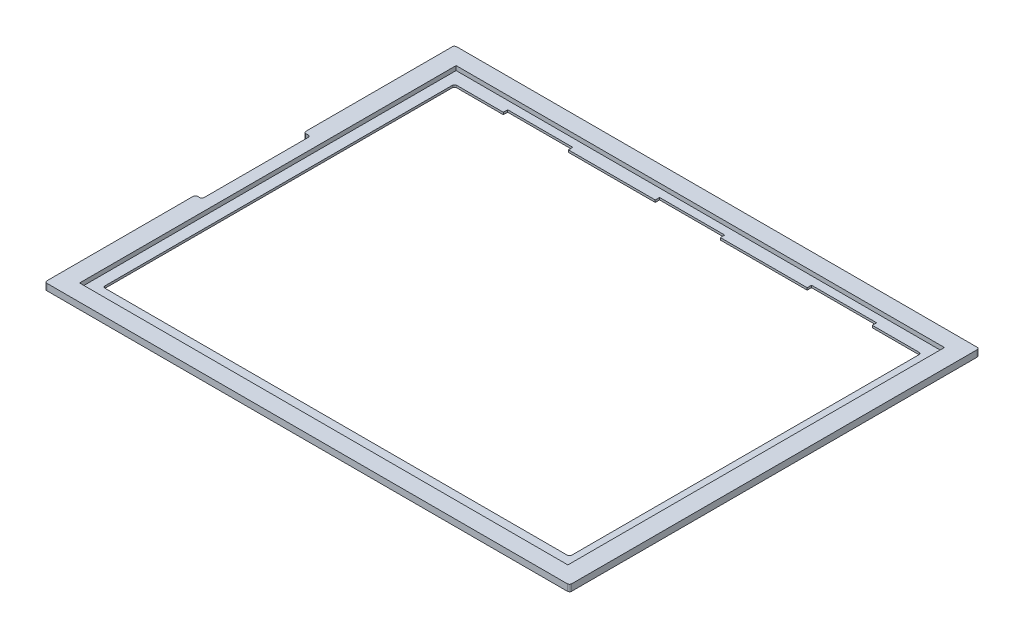
from build123d import *

# Parameters (mm, degrees)
SKETCH1_W           = 241.8
SKETCH1_H           = 188.8
SKETCH1_W_2         = 215
SKETCH1_H_2         = 162
BOSS_EXTRUDE1_DEPTH = 3
SKETCH2_W           = 225
SKETCH2_H           = 173.5
CUT_EXTRUDE1_DEPTH  = 2
SKETCH3_W           = 3
SKETCH3_H           = 50
CUT_EXTRUDE2_DEPTH  = 5
FILLET1_R           = 1
SKETCH4_W           = 30
SKETCH4_H           = 2
CUT_EXTRUDE3_DEPTH  = 4


with BuildPart() as part:
    # Sketch1 → Boss-Extrude1 (new body)
    with BuildSketch(Plane(origin=(0, 0, 0), x_dir=(1, 0, 0), z_dir=(0, 1, 0))):
        with Locations((120.9, 94.4)):
            Rectangle(SKETCH1_W, SKETCH1_H)
        with Locations((120.9, 94.4)):
            Rectangle(SKETCH1_W_2, SKETCH1_H_2, mode=Mode.SUBTRACT)
    extrude(amount=BOSS_EXTRUDE1_DEPTH)

    # Sketch2 → Cut-Extrude1 (cut)
    with BuildSketch(Plane(origin=(0, 3, 0), x_dir=(1, 0, 0), z_dir=(0, 1, 0))):
        with Locations((120.9, 94.4)):
            Rectangle(SKETCH2_W, SKETCH2_H)
    extrude(amount=-CUT_EXTRUDE1_DEPTH, mode=Mode.SUBTRACT)

    # Sketch3 → Cut-Extrude2 (cut)
    with BuildSketch(Plane(origin=(0, 3, 0), x_dir=(1, 0, 0), z_dir=(0, 1, 0))):
        with Locations((1.5, 94.4)):
            Rectangle(SKETCH3_W, SKETCH3_H)
    extrude(amount=-CUT_EXTRUDE2_DEPTH, mode=Mode.SUBTRACT)

    # Fillet1
    fillet1_edges = [part.edges().sort_by_distance(p)[0] for p in [
        (228.4, 0.5, -175.4),
        (13.4, 0.5, -175.4),
        (228.4, 0.5, -13.4),
        (13.4, 0.5, -13.4),
        (0, 1.5, -69.4),
        (0, 1.5, -119.4),
        (3, 1.5, -119.4),
        (3, 1.5, -69.4),
        (0, 1.5, -188.8),
        (241.8, 1.5, -188.8),
        (241.8, 1.5, 0),
        (0, 1.5, 0),
    ]]
    fillet(fillet1_edges, radius=FILLET1_R)

    # Sketch4 → Cut-Extrude3 (cut, through all)
    with BuildSketch(Plane.XZ):
        with Locations((50.9, -176.4)):
            Rectangle(SKETCH4_W, SKETCH4_H)
        with Locations((120.9, -176.4)):
            Rectangle(SKETCH4_W, SKETCH4_H)
        with Locations((190.9, -176.4)):
            Rectangle(SKETCH4_W, SKETCH4_H)
    extrude(amount=-CUT_EXTRUDE3_DEPTH, mode=Mode.SUBTRACT)


solid = part.part
